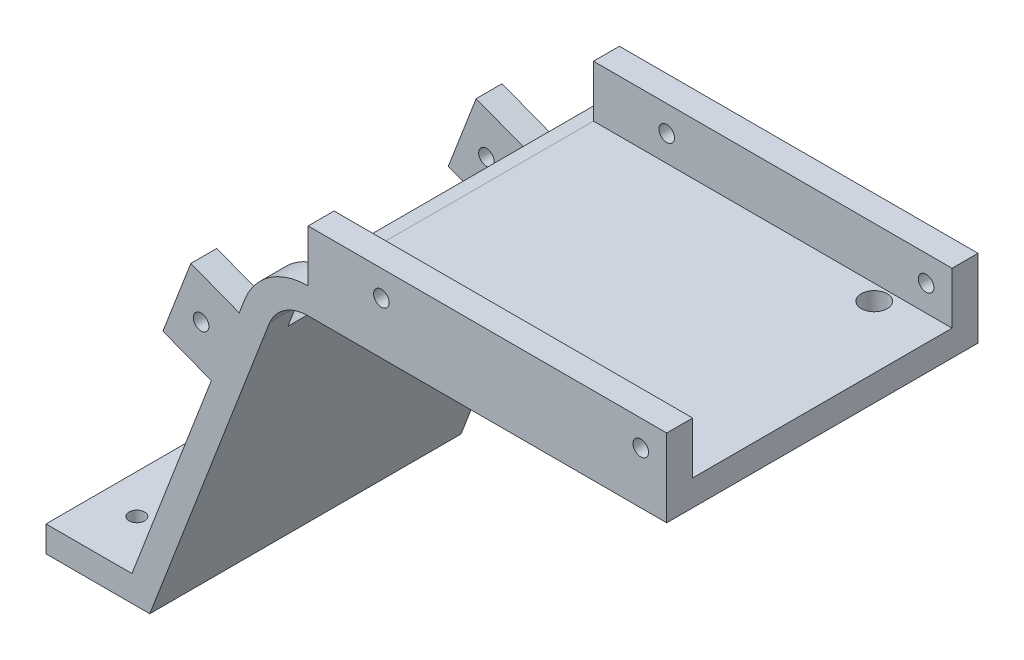
from build123d import *

# Parameters (mm, degrees)
SKETCH1_W               = 120
SKETCH1_H               = 100
BOSS_EXTRUDE1_DEPTH     = 5
SKETCH2_R               = 2.5
CUT_EXTRUDE1_DEPTH      = 6
CUT_EXTRUDE3_DEPTH      = 10
BOSS_EXTRUDE3_DEPTH     = 60
SKETCH8_W               = 20
SKETCH8_H               = 5
BOSS_EXTRUDE4_DEPTH     = 65
SKETCH9_R               = 2.5
CUT_EXTRUDE4_DEPTH      = 71
BOSS_EXTRUDE5_DEPTH     = 5
SKETCH11_W              = 5
SKETCH11_H              = 70
CUT_EXTRUDE6_DEPTH      = 1
CUT_EXTRUDE6_DEPTH_BACK = 120.643960247
SKETCH12_R              = 1.5
CUT_EXTRUDE7_DEPTH      = 66
CUT_EXTRUDE7_DEPTH_BACK = 6
SKETCH13_W              = 69.121998964
SKETCH13_H              = 5
BOSS_EXTRUDE6_DEPTH     = 10
SKETCH14_R              = 1.5
CUT_EXTRUDE8_DEPTH      = 61
SKETCH15_W              = 5
SKETCH15_H              = 15
BOSS_EXTRUDE7_DEPTH     = 10
SKETCH17_R              = 1.5
CUT_EXTRUDE9_DEPTH      = 61


with BuildPart() as part:
    # Sketch1 → Boss-Extrude1 (new body)
    with BuildSketch(Plane.XY):
        with Locations((60, 50)):
            Rectangle(SKETCH1_W, SKETCH1_H)
    extrude(amount=BOSS_EXTRUDE1_DEPTH)

    # Sketch2 → Cut-Extrude1 (cut, through all)
    with BuildSketch(Plane.XY.offset(5)):
        with Locations((50.878001036, 56.909722104)):
            Circle(SKETCH2_R)
        with BuildLine():
            ThreePointArc((85.579375435, 7.351023424), (95.403755905, 15.949898455), (103.154556632, 26.456286582))
            ThreePointArc((103.154556632, 26.456286582), (98.465291161, 44.232978888), (80.688598855, 39.543713418))
            ThreePointArc((80.688598855, 39.543713418), (76.268720755, 33.552467296), (70.66638809, 28.648976576))
            ThreePointArc((70.66638809, 28.648976576), (67.473905187, 10.543506327), (85.579375435, 7.351023424))
        make_face()
    extrude(amount=-CUT_EXTRUDE1_DEPTH, mode=Mode.SUBTRACT)

    # Sketch5 → Cut-Extrude3 (cut)
    with BuildSketch(Plane.XY.offset(5)):
        with BuildLine():
            Line((120, 70), (50.878001036, 70))
            ThreePointArc((50.878001036, 70), (43.464411706, 67.698330385), (38.657892056, 61.602728806))
            Line((38.657892056, 61.602728806), (15, 0))
            Line((15, 0), (0, 0))
            Line((0, 0), (0, 100))
            Line((0, 100), (120, 100))
            Line((120, 100), (120, 70))
        make_face()
    extrude(amount=-CUT_EXTRUDE3_DEPTH, mode=Mode.SUBTRACT)

    # Sketch7 → Boss-Extrude3 (add)
    with BuildSketch(Plane(origin=(0, 0, 0), x_dir=(-1, 0, 0), z_dir=(0, 0, -1))):
        Polygon((-15, 0), (-37.603180225, 58.856367181), (-41.980029807, 56.306656226), (-20.356039753, 0), align=None)
        with BuildLine():
            Line((-120, 70), (-50.878001036, 70))
            ThreePointArc((-50.878001036, 70), (-49.44782984, 69.92163917), (-48.034781184, 69.687494847))
            Line((-48.034781184, 69.687494847), (-51.317000411, 65))
            Line((-51.317000411, 65), (-120, 65))
            Line((-120, 65), (-120, 70))
        make_face()
    extrude(amount=BOSS_EXTRUDE3_DEPTH)

    # Sketch8 → Boss-Extrude4 (add, through all)
    with BuildSketch(Plane(origin=(0, 0, -60), x_dir=(-1, 0, 0), z_dir=(0, 0, -1))):
        with Locations((-10.356039753, 2.5)):
            Rectangle(SKETCH8_W, SKETCH8_H)
    extrude(amount=-BOSS_EXTRUDE4_DEPTH)

    # Sketch9 → Cut-Extrude4 (cut, through all)
    with BuildSketch(Plane(origin=(0, 70, 0), x_dir=(1, 0, 0), z_dir=(0, 1, 0))):
        with Locations((108, 52)):
            Circle(SKETCH9_R)
    extrude(amount=-CUT_EXTRUDE4_DEPTH, mode=Mode.SUBTRACT)

    # Sketch10 → Boss-Extrude5 (add)
    with BuildSketch(Plane(origin=(0, 0, 0), x_dir=(-1, 0, 0), z_dir=(0, 0, -1))):
        with BuildLine():
            Line((-38.657892056, 61.602728806), (-37.603180225, 58.856367181))
            Line((-37.603180225, 58.856367181), (-41.980029807, 56.306656226))
            Line((-41.980029807, 56.306656226), (-43.482905887, 60.219991674))
            ThreePointArc((-43.482905887, 60.219991674), (-46.657937411, 63.826106989), (-51.317000411, 65))
            Line((-51.317000411, 65), (-48.034781184, 69.687494847))
            ThreePointArc((-48.034781184, 69.687494847), (-42.330087293, 66.823780104), (-38.657892056, 61.602728806))
        make_face()
    extrude(amount=BOSS_EXTRUDE5_DEPTH)

    # Sketch11 → Cut-Extrude6 (cut, two sides)
    with BuildSketch(Plane(origin=(120, 0, 0), x_dir=(0, 0, -1), z_dir=(1, 0, 0))) as cut_extrude6_sk:
        with Locations((-2.5, 35)):
            Rectangle(SKETCH11_W, SKETCH11_H)
    extrude(amount=CUT_EXTRUDE6_DEPTH, mode=Mode.SUBTRACT)
    extrude(cut_extrude6_sk.sketch, amount=-CUT_EXTRUDE6_DEPTH_BACK, mode=Mode.SUBTRACT)

    # Sketch12 → Cut-Extrude7 (cut, two sides)
    with BuildSketch(Plane(origin=(0, 5, 0), x_dir=(1, 0, 0), z_dir=(0, 1, 0))) as cut_extrude7_sk:
        with Locations((7.856039753, 10)):
            Circle(SKETCH12_R)
        with Locations((7.856039753, 50)):
            Circle(SKETCH12_R)
    extrude(amount=CUT_EXTRUDE7_DEPTH, mode=Mode.SUBTRACT)
    extrude(cut_extrude7_sk.sketch, amount=-CUT_EXTRUDE7_DEPTH_BACK, mode=Mode.SUBTRACT)

    # Sketch13 → Boss-Extrude6 (add)
    with BuildSketch(Plane(origin=(0, 70, 0), x_dir=(1, 0, 0), z_dir=(0, 1, 0))):
        with Locations((85.439000518, 2.5)):
            Rectangle(SKETCH13_W, SKETCH13_H)
        with Locations((85.439000518, 57.5)):
            Rectangle(SKETCH13_W, SKETCH13_H)
    extrude(amount=BOSS_EXTRUDE6_DEPTH)

    # Sketch14 → Cut-Extrude8 (cut, through all)
    with BuildSketch(Plane.XY):
        with Locations((65, 75)):
            Circle(SKETCH14_R)
        with Locations((115, 75)):
            Circle(SKETCH14_R)
    extrude(amount=-CUT_EXTRUDE8_DEPTH, mode=Mode.SUBTRACT)

    # Sketch15 → Boss-Extrude7 (add)
    with BuildSketch(Plane(origin=(13.072049518, -5.020185671, 0), x_dir=(0, 0, 1), z_dir=(-0.933525558, 0.358510854, 0))):
        with Locations((-2.5, 60.925071268)):
            Rectangle(SKETCH15_W, SKETCH15_H)
        with Locations((-57.5, 60.925071268)):
            Rectangle(SKETCH15_W, SKETCH15_H)
    extrude(amount=BOSS_EXTRUDE7_DEPTH)

    # Sketch17 → Cut-Extrude9 (cut, through all)
    with BuildSketch(Plane.XY):
        with Locations((30.246721032, 53.647479763)):
            Circle(SKETCH17_R)
    extrude(amount=-CUT_EXTRUDE9_DEPTH, mode=Mode.SUBTRACT)


solid = part.part
